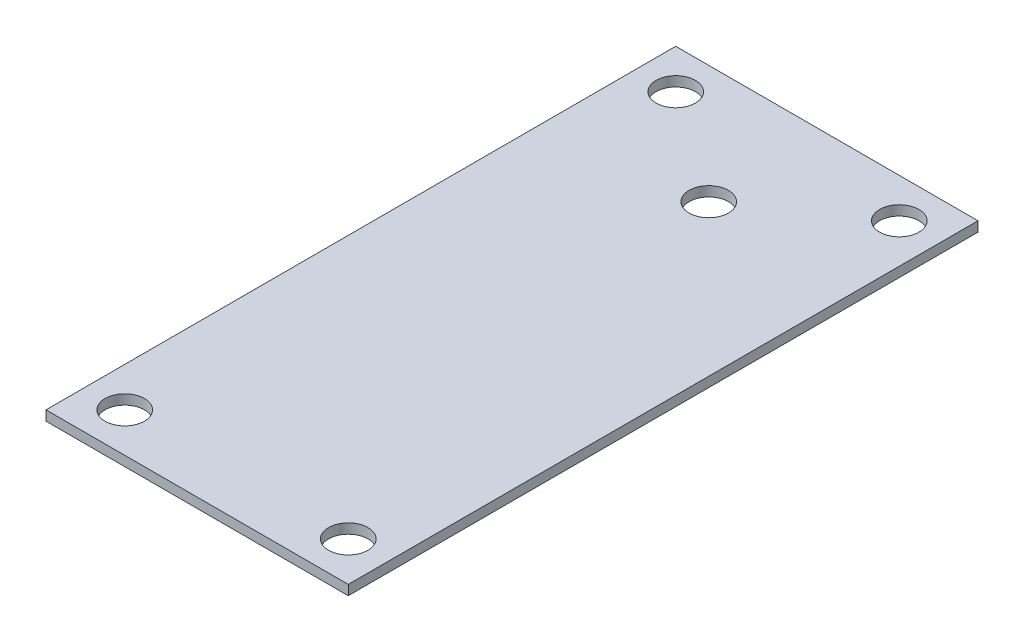
from build123d import *

# Parameters (mm, degrees)
SKETCH1_W           = 48.768
SKETCH1_H           = 101.6
SKETCH1_R           = 3.175
BOSS_EXTRUDE1_DEPTH = 1.5875
CUT_EXTRUDE1_REACH  = 3.587
SKETCH2_R           = 3.175


with BuildPart() as part:
    # Sketch1 → Boss-Extrude1 (new body)
    with BuildSketch(Plane(origin=(0, 0, 0), x_dir=(1, 0, 0), z_dir=(0, 1, 0))):
        Rectangle(SKETCH1_W, SKETCH1_H)
        with Locations((-18.034, 44.45)):
            Circle(SKETCH1_R, mode=Mode.SUBTRACT)
        with Locations((18.034, 44.45)):
            Circle(SKETCH1_R, mode=Mode.SUBTRACT)
        with Locations((18.034, -44.45)):
            Circle(SKETCH1_R, mode=Mode.SUBTRACT)
        with Locations((-18.034, -44.45)):
            Circle(SKETCH1_R, mode=Mode.SUBTRACT)
    extrude(amount=BOSS_EXTRUDE1_DEPTH)

    # Sketch2 → Cut-Extrude1 (cut, up to next)
    with BuildSketch(Plane(origin=(0, 1.5875, 0), x_dir=(1, 0, 0), z_dir=(0, 1, 0)), mode=Mode.PRIVATE) as cut_extrude1_sk1:
        with Locations((0, 31.75)):
            Circle(SKETCH2_R)
    cut_extrude1_tool1 = extrude(cut_extrude1_sk1.sketch, amount=-CUT_EXTRUDE1_REACH, mode=Mode.PRIVATE) & part.part
    add(cut_extrude1_tool1.solids().sort_by_distance((0, 1.5875, -31.75))[0], mode=Mode.SUBTRACT)


solid = part.part
